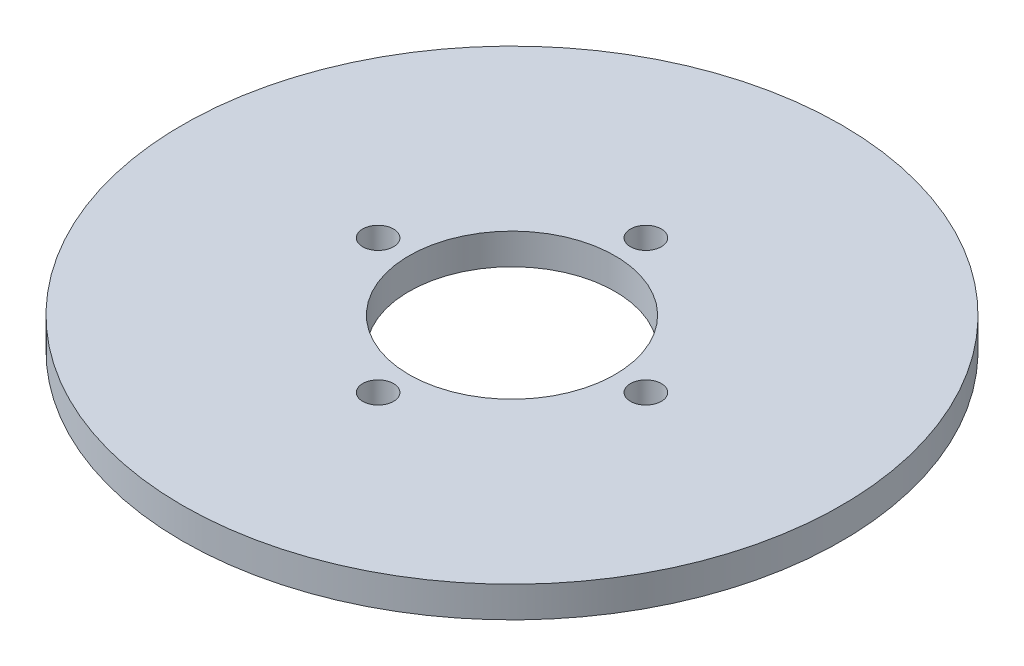
from build123d import *

# Parameters (mm, degrees)
SKETCH1_R           = 32
BOSS_EXTRUDE1_DEPTH = 3
SKETCH2_R           = 10
CUT_EXTRUDE1_DEPTH  = 10
SKETCH3_R           = 1.5
CUT_EXTRUDE2_DEPTH  = 4


with BuildPart() as part:
    # Sketch1 → Boss-Extrude1 (new body)
    with BuildSketch(Plane(origin=(0, 0, 0), x_dir=(1, 0, 0), z_dir=(0, 1, 0))):
        Circle(SKETCH1_R)
    extrude(amount=BOSS_EXTRUDE1_DEPTH)

    # Sketch2 → Cut-Extrude1 (cut)
    with BuildSketch(Plane(origin=(0, 3, 0), x_dir=(1, 0, 0), z_dir=(0, 1, 0))):
        Circle(SKETCH2_R)
    extrude(amount=-CUT_EXTRUDE1_DEPTH, mode=Mode.SUBTRACT)

    # Sketch3 → Cut-Extrude2 (cut, through all)
    with BuildSketch(Plane.XZ):
        with Locations((13, 0)):
            Circle(SKETCH3_R)
        with Locations((0, -13)):
            Circle(SKETCH3_R)
        with Locations((-13, 0)):
            Circle(SKETCH3_R)
        with Locations((0, 13)):
            Circle(SKETCH3_R)
    extrude(amount=-CUT_EXTRUDE2_DEPTH, mode=Mode.SUBTRACT)


solid = part.part
